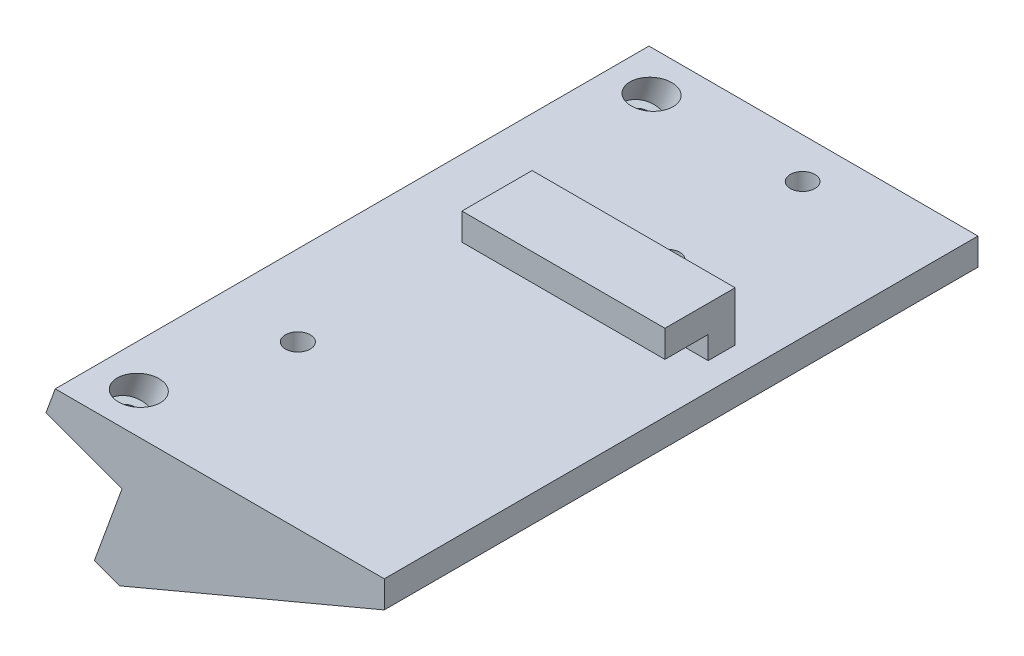
from build123d import *

# Parameters (mm, degrees)
EXTRUDE_1_DEPTH        = 65
EXTRUDE_2_DEPTH        = 5
EXTRUDE_3_DEPTH        = 8
SKETCH_8_R             = 2.3
CUT_EXTRUDE_4_DEPTH    = 3.5
CUT_EXTRUDE_6_DEPTH    = 14
EXTRUDE_4_DEPTH        = 40
HOLE_WIZARD_M4_1_D     = 4.5
HOLE_WIZARD_M4_1_DEPTH = 10
HOLE_WIZARD_M4_1_TIP   = 1.351936393
CUT_EXTRUDE_START      = -2
SKETCH_16_R            = 3.75
CUT_EXTRUDE_7_DEPTH    = 33.495632075
F_4_0MM_1_D            = 4.55
F_4_0MM_1_DEPTH        = 3.5
CUT_EXTRUDE_8_DEPTH    = 5


with BuildPart() as part:
    # ｽｹｯﾁ1 → ﾎﾞｽ - 押し出し1 (new body)
    with BuildSketch(Plane.XY):
        Polygon((0, 0), (5.13030215, 14.095389312), (-8.965087162, 19.225691462), (-7.254986445, 23.924154566), (53.707680142, 23.924154566), (53.707680142, 18.924154566), (4.698463104, -1.710100717), align=None)
    extrude(amount=EXTRUDE_1_DEPTH)

    # ｽｹｯﾁ6 → ﾎﾞｽ - 押し出し2 (add)
    with BuildSketch(Plane(origin=(0, 0, 0), x_dir=(-1, 0, 0), z_dir=(0, 0, -1))):
        Polygon((-53.707680142, 33.124154566), (-53.707680142, 18.924154566), (-4.698463104, -1.710100717), (0, 0), (-5.13030215, 14.095389312), (8.965087162, 19.225691462), (3.90646029, 33.124154566), align=None)
    extrude(amount=EXTRUDE_2_DEPTH)

    # ｽｹｯﾁ7 → ﾎﾞｽ - 押し出し3 (add)
    with BuildSketch(Plane.XY):
        Polygon((-3.90646029, 33.124154566), (-5.726311461, 28.124154566), (53.707680142, 28.124154566), (53.707680142, 33.124154566), align=None)
    extrude(amount=EXTRUDE_3_DEPTH)

    # ｽｹｯﾁ8 → ｶｯﾄ - 押し出し4 (cut)
    with BuildSketch(Plane(origin=(0, 23.924154566, 0), x_dir=(1, 0, 0), z_dir=(0, 1, 0))):
        with Locations((7.695013555, -35)):
            Circle(SKETCH_8_R)
    extrude(amount=-CUT_EXTRUDE_4_DEPTH, mode=Mode.SUBTRACT)

    # ｽｹｯﾁ12 → ｶｯﾄ - 押し出し6 (cut, through all)
    with BuildSketch(Plane.XY.offset(8)):
        Polygon((-3.90646029, 33.124154566), (-7.254986445, 23.924154566), (11.09353971, 23.924154566), (11.09353971, 33.124154566), align=None)
    extrude(amount=-CUT_EXTRUDE_6_DEPTH, mode=Mode.SUBTRACT)

    # ｽｹｯﾁ13 → ﾎﾞｽ - 押し出し4 (add)
    with BuildSketch(Plane(origin=(0, 0, -5), x_dir=(-1, 0, 0), z_dir=(0, 0, -1))):
        Polygon((-4.698463104, -1.710100717), (0, 0), (-5.13030215, 14.095389312), (8.965087162, 19.225691462), (7.254986445, 23.924154566), (-53.707680142, 23.924154566), (-53.707680142, 18.924154566), align=None)
    extrude(amount=EXTRUDE_4_DEPTH)

    # M4 すきま穴1
    with Locations(Plane(origin=(5.13030215, 14.095389312, 0), x_dir=(-0.939692621, 0.342020143, 0), z_dir=(-0.342020143, -0.939692621, 0))):
        with Locations((7.5, -57.5), (7.5, 37.5)):
            Hole(HOLE_WIZARD_M4_1_D / 2, depth=HOLE_WIZARD_M4_1_DEPTH)
            with Locations((0, 0, -(HOLE_WIZARD_M4_1_DEPTH + HOLE_WIZARD_M4_1_TIP / 2))):  # 118° drill point
                Cone(0, HOLE_WIZARD_M4_1_D / 2, HOLE_WIZARD_M4_1_TIP, mode=Mode.SUBTRACT)

    # ｽｹｯﾁ16 → ｶｯﾄ - 押し出し7 (cut, through all)
    with BuildSketch(Plane(origin=(5.13030215, 14.095389312, 0), x_dir=(0.939692621, -0.342020143, 0), z_dir=(-0.342020143, -0.939692621, 0)).offset(CUT_EXTRUDE_START)):
        with Locations((-7.5, 57.5)):
            Circle(SKETCH_16_R)
        with Locations((-7.5, -37.5)):
            Circle(SKETCH_16_R)
    extrude(amount=-CUT_EXTRUDE_7_DEPTH, mode=Mode.SUBTRACT)

    # Ø4.0mm ﾀﾞｳｴﾙ穴1
    with Locations(Plane(origin=(0, 23.924154566, 0), x_dir=(1, 0, 0), z_dir=(0, 1, 0))):
        with Locations((28.707680142, 37.5), (28.707680142, 12.5)):
            Hole(F_4_0MM_1_D / 2, depth=F_4_0MM_1_DEPTH)

    # ｽｹｯﾁ19 → ｶｯﾄ - 押し出し8 (cut)
    with BuildSketch(Plane(origin=(53.707680142, 0, 0), x_dir=(0, 0, -1), z_dir=(1, 0, 0))):
        Polygon((0, 23.924154566), (5, 23.924154566), (5, 33.124154566), (-8, 33.124154566), (-8, 28.124154566), (0, 28.124154566), align=None)
    extrude(amount=-CUT_EXTRUDE_8_DEPTH, mode=Mode.SUBTRACT)


solid = part.part
